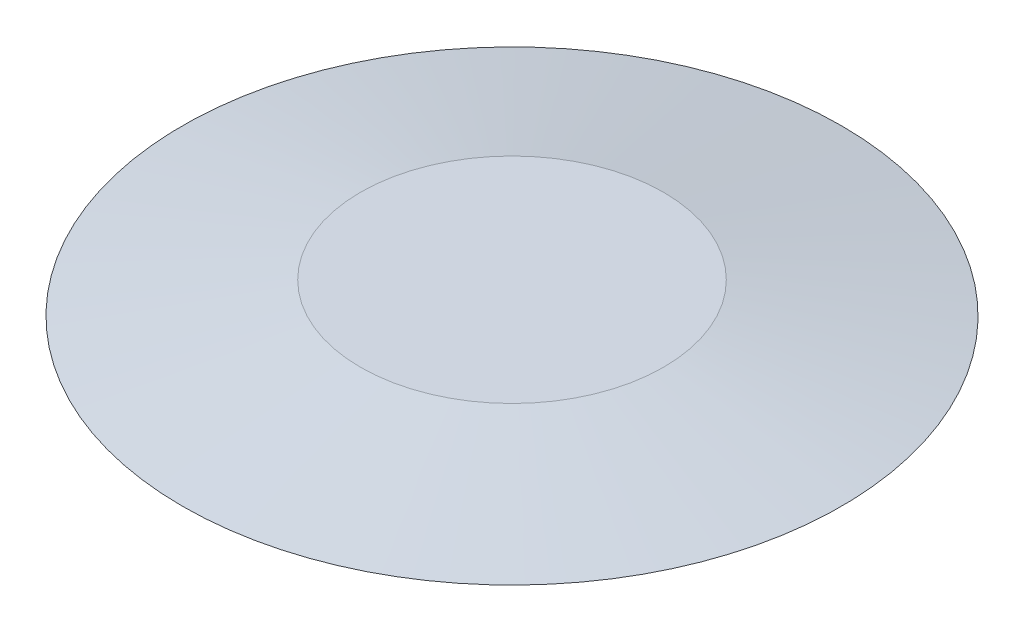
from build123d import *

# Parameters (mm, degrees)
CROQUIS1_R              = 26.67
SALIENTE_EXTRUIR1_DEPTH = 2.54
SALIENTE_EXTRUIR1_TAPER = 80


with BuildPart() as part:
    # Croquis1 → Saliente-Extruir1 (new body)
    with BuildSketch(Plane(origin=(0, 0, 0), x_dir=(1, 0, 0), z_dir=(0, 1, 0))):
        Circle(CROQUIS1_R)
    extrude(amount=SALIENTE_EXTRUIR1_DEPTH, taper=SALIENTE_EXTRUIR1_TAPER)


solid = part.part
